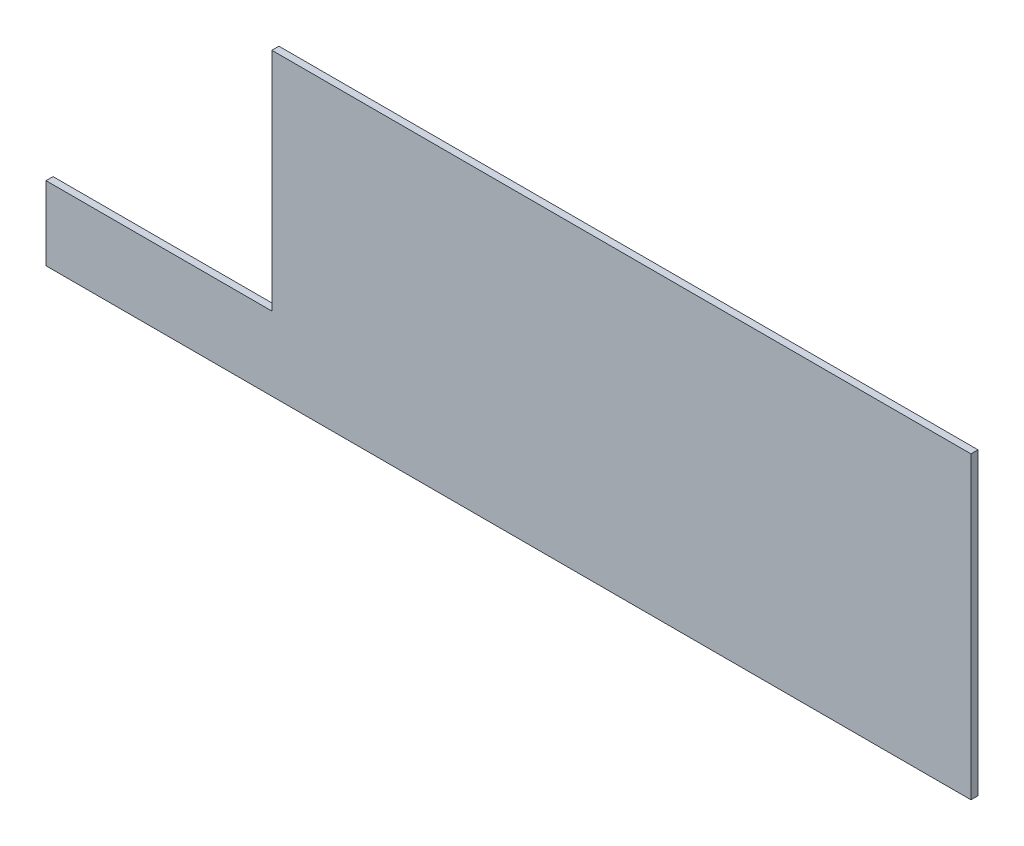
from build123d import *

# Parameters (mm, degrees)
BOSS_EXTRUDE1_DEPTH = 3.175


with BuildPart() as part:
    # Sketch1 → Boss-Extrude1 (new body)
    with BuildSketch(Plane.XY):
        Polygon((-24.07467481, 111.148523924), (-24.07467481, 9.548523924), (-125.67467481, 9.548523924), (-125.67467481, -23.626476076), (290.40532519, -23.626476076), (290.40532519, 111.148523924), align=None)
    extrude(amount=BOSS_EXTRUDE1_DEPTH)


solid = part.part
